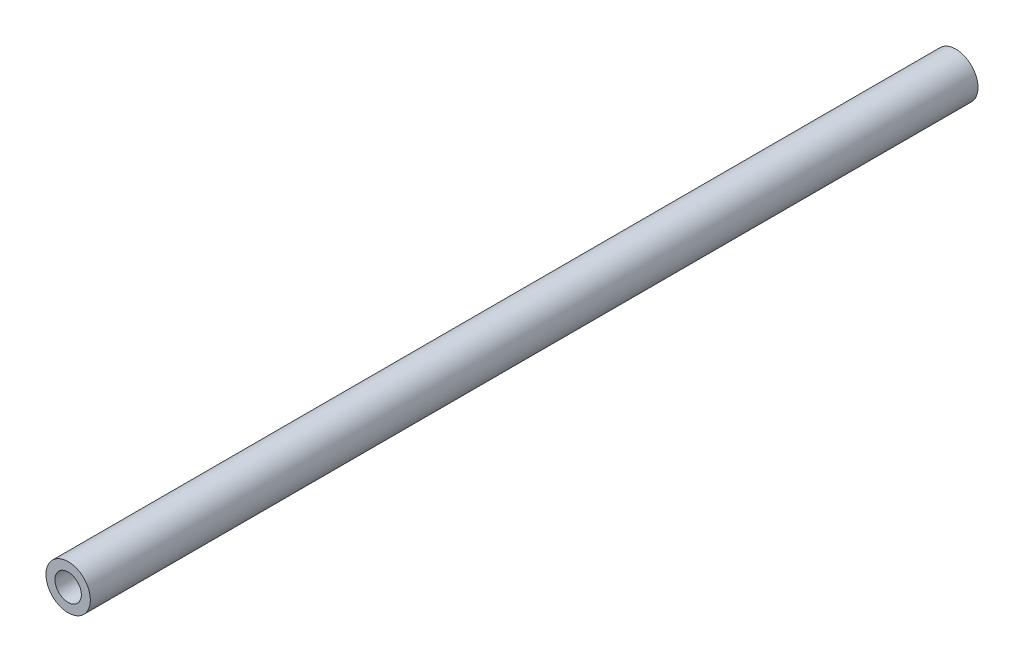
from build123d import *

# Parameters (mm, degrees)
SKETCH1_R           = 8
BOSS_EXTRUDE1_DEPTH = 320
SKETCH2_R           = 4.755
CUT_EXTRUDE1_DEPTH  = 321


with BuildPart() as part:
    # Sketch1 → Boss-Extrude1 (new body)
    with BuildSketch(Plane.XY):
        Circle(SKETCH1_R)
    extrude(amount=BOSS_EXTRUDE1_DEPTH)

    # Sketch2 → Cut-Extrude1 (cut, through all)
    with BuildSketch(Plane(origin=(0, 0, 0), x_dir=(-1, 0, 0), z_dir=(0, 0, -1))):
        Circle(SKETCH2_R)
    extrude(amount=-CUT_EXTRUDE1_DEPTH, mode=Mode.SUBTRACT)


solid = part.part
